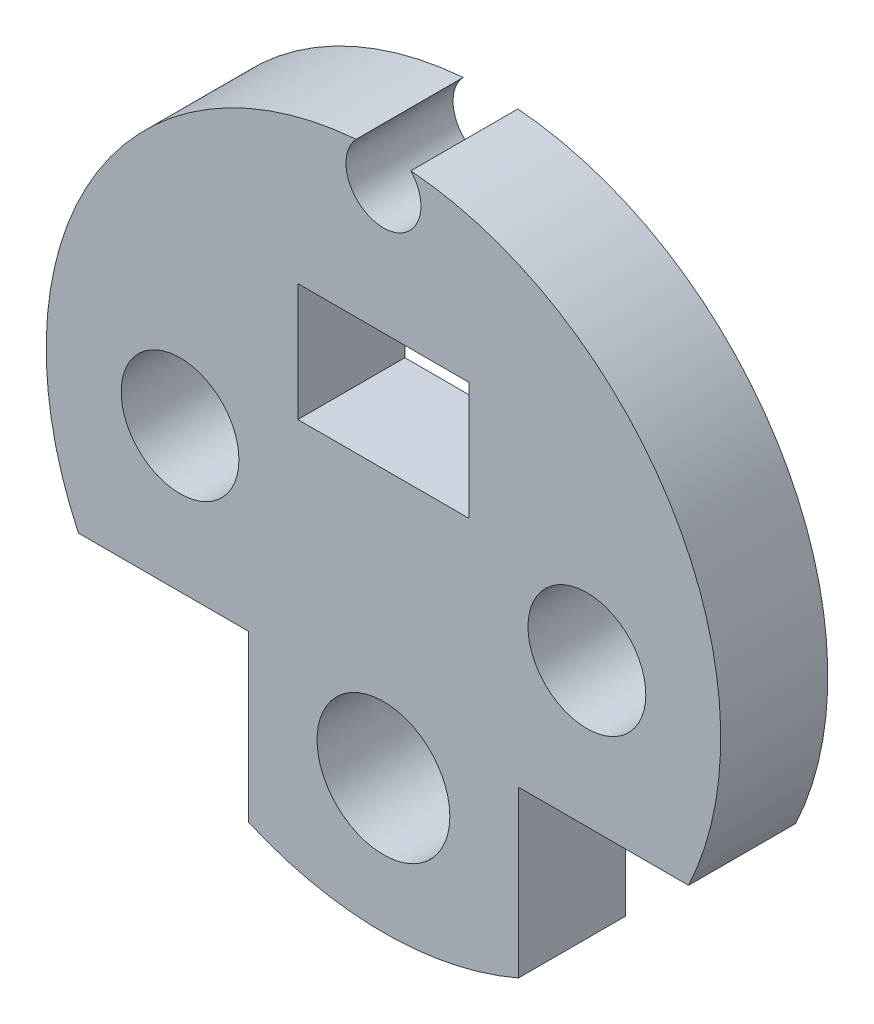
from build123d import *

# Parameters (mm, degrees)
ESQUISSE1_R             = 15.75
BOSS_EXTRU_1_DEPTH      = 5
ESQUISSE2_W             = 5.5
ESQUISSE2_H             = 2.985070052
BOSS_EXTRU_2_DEPTH      = 2.7
ESQUISSE3_R             = 1.75
ESQUISSE3_R_2           = 2.75
ESQUISSE3_R_3           = 3.1
ENL_V_MAT_EXTRU_1_DEPTH = 6
ESQUISSE4_W             = 7.942495838
ESQUISSE4_H             = 7.71802451
ENL_V_MAT_EXTRU_2_DEPTH = 6
ESQUISSE5_W             = 8
ESQUISSE5_H             = 5.5
ENL_V_MAT_EXTRU_3_DEPTH = 6


with BuildPart() as part:
    # Esquisse1 → Boss.-Extru.1 (new body)
    with BuildSketch(Plane.XY):
        Circle(ESQUISSE1_R)
    extrude(amount=BOSS_EXTRU_1_DEPTH)

    # Esquisse2 → Boss.-Extru.2 (add)
    with BuildSketch(Plane(origin=(0, 0, 0), x_dir=(-1, 0, 0), z_dir=(0, 0, -1))):
        with Locations((0, -15.007464974)):
            Rectangle(ESQUISSE2_W, ESQUISSE2_H)
    extrude(amount=-BOSS_EXTRU_2_DEPTH)

    # Esquisse3 → Enlèv. mat.-Extru.1 (cut, through all)
    with BuildSketch(Plane.XY.offset(5)):
        with Locations((0, 14.5)):
            Circle(ESQUISSE3_R)
        with Locations((9.5, 0)):
            Circle(ESQUISSE3_R_2)
        with Locations((-9.5, 0)):
            Circle(ESQUISSE3_R_2)
        with Locations((0, -9.5)):
            Circle(ESQUISSE3_R_3)
    extrude(amount=-ENL_V_MAT_EXTRU_1_DEPTH, mode=Mode.SUBTRACT)

    # Esquisse4 → Enlèv. mat.-Extru.2 (cut, through all)
    with BuildSketch(Plane.XY.offset(5)):
        with Locations((-10.275426072, -10.574276969)):
            Rectangle(ESQUISSE4_W, ESQUISSE4_H)
    enl_v_mat_extru_2 = extrude(amount=-ENL_V_MAT_EXTRU_2_DEPTH, mode=Mode.SUBTRACT)

    # Symétrie1: Enlèv. mat.-Extru.2 across plane
    add(enl_v_mat_extru_2.mirror(Plane(origin=(0, 0, 0), x_dir=(0, 0, 1), z_dir=(1, 0, 0))), mode=Mode.SUBTRACT)

    # Esquisse5 → Enlèv. mat.-Extru.3 (cut, through all)
    with BuildSketch(Plane.XY.offset(5)):
        with Locations((0, 5.75)):
            Rectangle(ESQUISSE5_W, ESQUISSE5_H)
    extrude(amount=-ENL_V_MAT_EXTRU_3_DEPTH, mode=Mode.SUBTRACT)


solid = part.part
